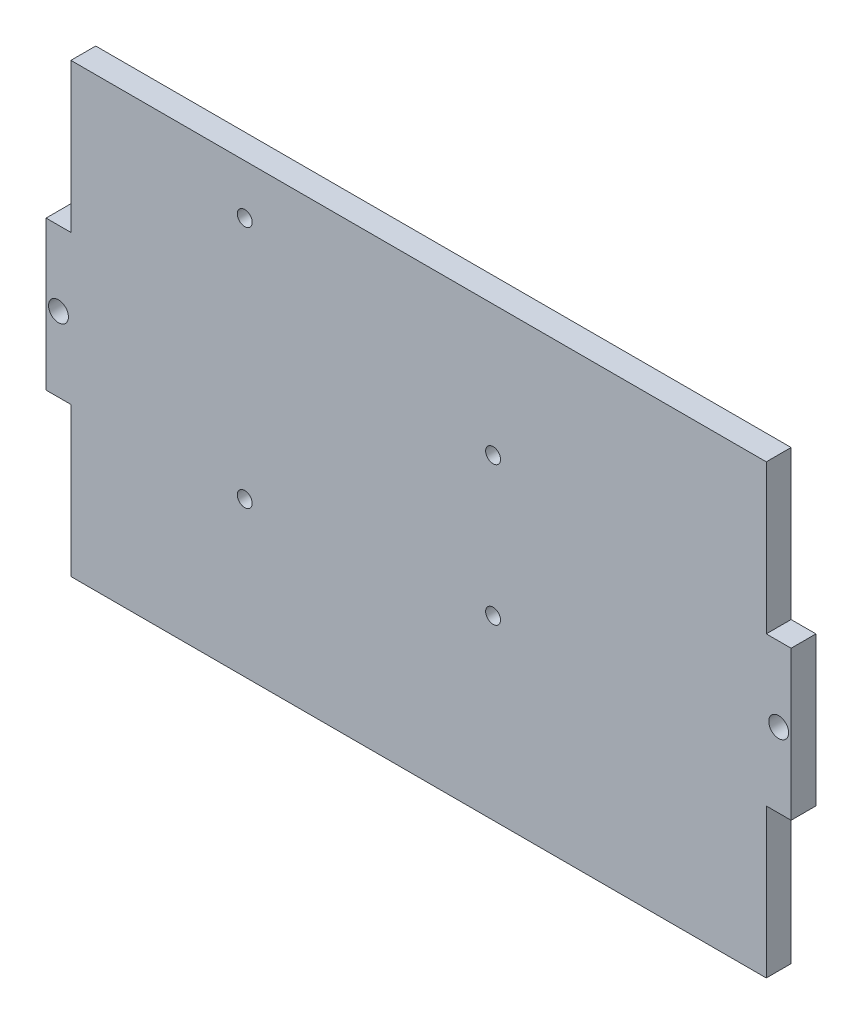
from build123d import *

# Parameters (mm, degrees)
BOSS_EXTRUDE1_DEPTH = 5
SKETCH2_R           = 1.5
CUT_EXTRUDE1_DEPTH  = 10
SKETCH3_R           = 2
CUT_EXTRUDE2_DEPTH  = 10


with BuildPart() as part:
    # Sketch1 → Boss-Extrude1 (new body)
    with BuildSketch(Plane.XY):
        Polygon((-75, -15), (-70, -15), (-70, -45), (70, -45), (70, -15), (75, -15), (75, 15), (70, 15), (70, 45), (-70, 45), (-70, 15), (-75, 15), align=None)
    extrude(amount=BOSS_EXTRUDE1_DEPTH)

    # Sketch2 → Cut-Extrude1 (cut)
    with BuildSketch(Plane.XY.offset(5)):
        with Locations((15, 18.66)):
            Circle(SKETCH2_R)
        with Locations((15, -9.34)):
            Circle(SKETCH2_R)
        with Locations((-35, 35)):
            Circle(SKETCH2_R)
        with Locations((-35, -14)):
            Circle(SKETCH2_R)
    extrude(amount=-CUT_EXTRUDE1_DEPTH, mode=Mode.SUBTRACT)

    # Sketch3 → Cut-Extrude2 (cut)
    with BuildSketch(Plane.XY.offset(5)):
        with Locations((-72.5, 0)):
            Circle(SKETCH3_R)
        with Locations((72.5, 0)):
            Circle(SKETCH3_R)
    extrude(amount=-CUT_EXTRUDE2_DEPTH, mode=Mode.SUBTRACT)


solid = part.part
